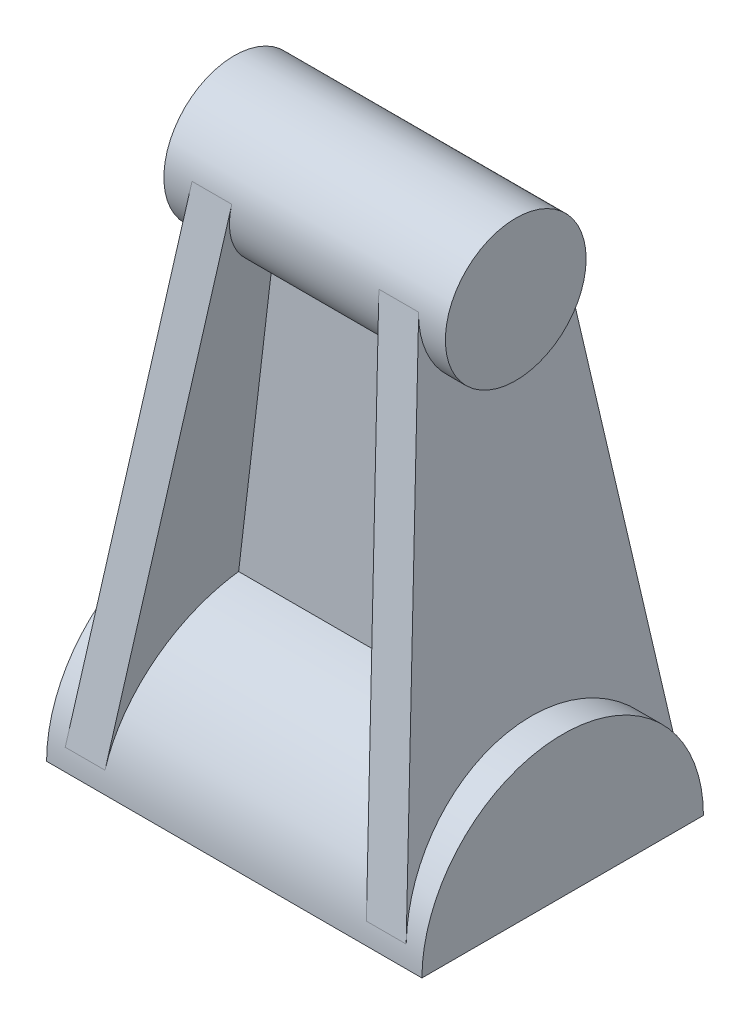
from build123d import *

# Parameters (mm, degrees)
SKETCH1_R                = 14.25
BOSS_EXTRUDE1_DEPTH      = 28.5
BOSS_EXTRUDE2_DEPTH      = 38
BOSS_EXTRUDE3_DEPTH      = 28.5
BOSS_EXTRUDE3_DEPTH_BACK = 28.5
SKETCH3_OUTSIDE_W        = 88.718
SKETCH3_OUTSIDE_H        = 145.968
CUT_EXTRUDE1_DEPTH       = 39
BOSS_EXTRUDE5_DEPTH      = 4


with BuildPart() as part:
    # Sketch1 → Boss-Extrude1 (new body, symmetric)
    with BuildSketch(Plane(origin=(0, 0, 0), x_dir=(0, 0, -1), z_dir=(1, 0, 0))):
        with Locations((0, 100)):
            Circle(SKETCH1_R)
    extrude(amount=BOSS_EXTRUDE1_DEPTH, both=True)



with BuildPart() as body_2:
    # Sketch1_3 → Boss-Extrude2 (new body, symmetric)
    with BuildSketch(Plane(origin=(0, 0, 0), x_dir=(0, 0, -1), z_dir=(1, 0, 0))):
        with BuildLine():
            Line((-28.5, 0), (28.5, 0))
            ThreePointArc((28.5, 0), (0, 28.5), (-28.5, 0))
        make_face()
    extrude(amount=BOSS_EXTRUDE2_DEPTH, both=True)


with BuildPart() as body_3:
    # Sketch2 → Boss-Extrude3 (new body, two sides)
    with BuildSketch(Plane.XY) as boss_extrude3_sk:
        Polygon((13.444344632, 114.25), (21.5, 114.25), (35, 0), (26.944344632, 0), align=None)
    extrude(amount=BOSS_EXTRUDE3_DEPTH)
    extrude(boss_extrude3_sk.sketch, amount=-BOSS_EXTRUDE3_DEPTH_BACK)

    # Sketch3 outside → Cut-Extrude1 (cut, through all)
    with BuildSketch(Plane(origin=(0, 0, 0), x_dir=(0, 0, -1), z_dir=(1, 0, 0))):
        with Locations((0, 57.125)):
            Rectangle(SKETCH3_OUTSIDE_W, SKETCH3_OUTSIDE_H)
        Polygon((14.104575928, 102.030625), (-14.104575928, 102.030625), (-28.209151856, 4.06125), (28.209151856, 4.06125), align=None, mode=Mode.SUBTRACT)
    extrude(amount=CUT_EXTRUDE1_DEPTH, mode=Mode.SUBTRACT)


with BuildPart() as body_4:
    # Mirror1: mirrored copy
    add(body_3.part.mirror(Plane(origin=(0, 0, 0), x_dir=(0, 0, 1), z_dir=(1, 0, 0))))


with BuildPart() as part_1:
    add(part.part)

    add(body_2.part)  # Boss-Extrude5 merges body 2

    add(body_3.part)  # Boss-Extrude5 merges body 3

    add(body_4.part)  # Boss-Extrude5 merges body 4
    # Sketch4 → Boss-Extrude5 (add, symmetric)
    with BuildSketch(Plane.XY):
        Polygon((-14.888209512, 102.030625), (14.888209512, 102.030625), (26.464459512, 4.06125), (-26.464459512, 4.06125), align=None)
    extrude(amount=BOSS_EXTRUDE5_DEPTH, both=True)


solid = part_1.part
